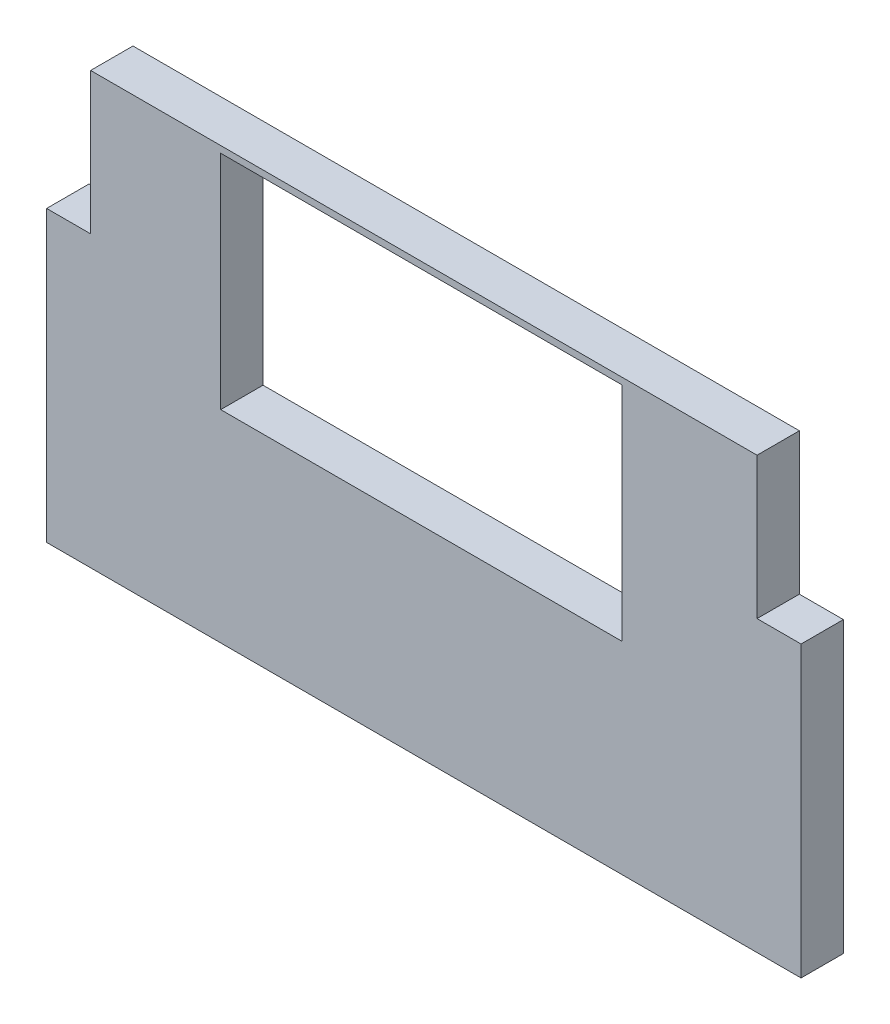
from build123d import *

# Parameters (mm, degrees)
SKETCH1_W           = 30.1
SKETCH1_H           = 16.66
BOSS_EXTRUDE1_DEPTH = 3.175


with BuildPart() as part:
    # Sketch1 → Boss-Extrude1 (new body)
    with BuildSketch(Plane.XY):
        Polygon((-7.623587917, 2.211285499), (-7.623587917, 23.913285529), (-4.321587917, 23.913285529), (-4.321587917, 34.531285499), (45.678412083, 34.531285499), (45.678412083, 23.913285529), (48.980412083, 23.913285529), (48.980412083, 2.211285499), align=None)
        with Locations((20.488412083, 25.701285499)):
            Rectangle(SKETCH1_W, SKETCH1_H, mode=Mode.SUBTRACT)
    extrude(amount=BOSS_EXTRUDE1_DEPTH)


solid = part.part
